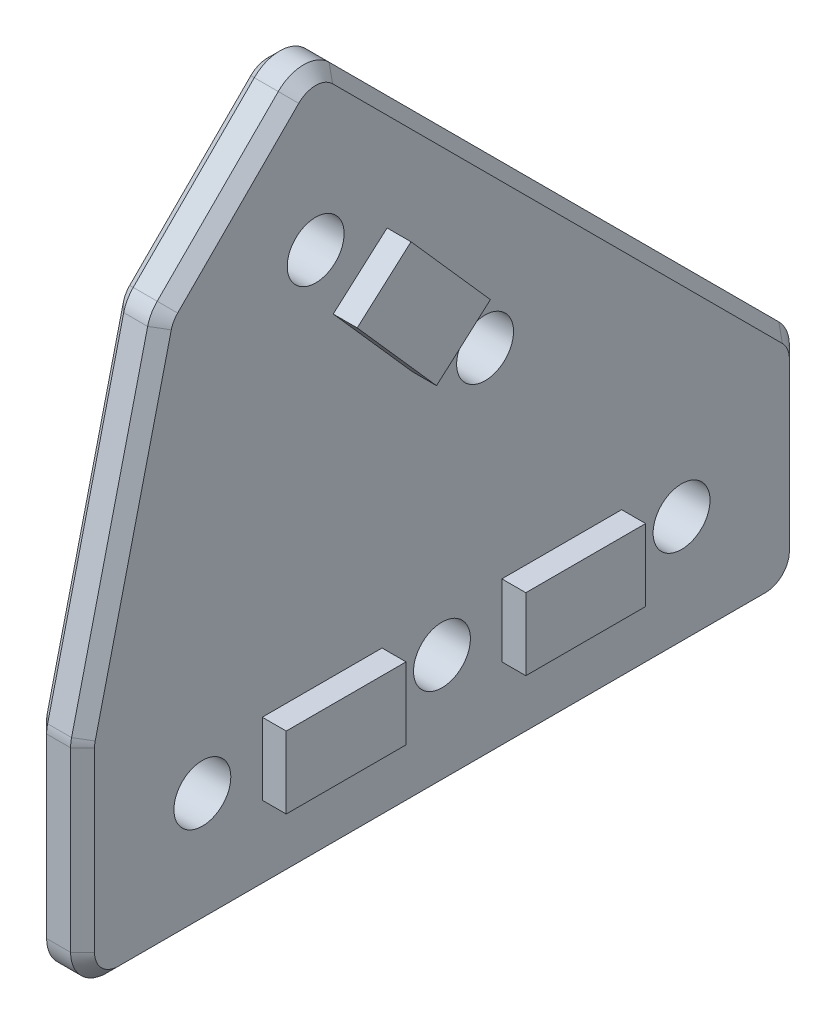
from build123d import *

# Parameters (mm, degrees)
BOSS_EXTRUDE1_DEPTH      = 4
SKETCH2_R                = 2.375
CUT_EXTRUDE1_DEPTH       = 98.803788642
LPATTERN1_COUNT          = 3
LPATTERN1_PITCH          = 20
SKETCH2_4_R              = 2.375
CUT_EXTRUDE2_DEPTH       = 98.803788642
LPATTERN2_COUNT          = 2
LPATTERN2_PITCH          = 20
FILLET1_R                = 3
CHANFRO1_SIZE            = 1
ESBO_O1_W                = 10
ESBO_O1_H                = 6
RESSALTO_EXTRUS_O1_DEPTH = 2


with BuildPart() as part:
    # Sketch1 → Boss-Extrude1 (new body)
    with BuildSketch(Plane(origin=(0, 0, 0), x_dir=(0, 0, -1), z_dir=(1, 0, 0))):
        Polygon((-78.140120378, 0), (-18.140120378, 0), (-18.140120378, 18.140120378), (-58.68306962, 58.68306962), (-71.510071751, 45.856067489), (-78.140120378, 18.140120378), align=None)
    extrude(amount=BOSS_EXTRUDE1_DEPTH)

    # Sketch2 → Cut-Extrude1 (cut, through all)
    with BuildSketch(Plane(origin=(4, 0, 0), x_dir=(0, 0, -1), z_dir=(1, 0, 0))):
        with Locations((-28.140120378, 10)):
            Circle(SKETCH2_R)
    cut_extrude1 = extrude(amount=-CUT_EXTRUDE1_DEPTH, mode=Mode.SUBTRACT)

    # LPattern1: Cut-Extrude1 ×3
    with Locations(*[(0, 0, i * LPATTERN1_PITCH) for i in range(1, LPATTERN1_COUNT)]):
        add(cut_extrude1, mode=Mode.SUBTRACT)

    # Sketch2_4 → Cut-Extrude2 (cut, through all)
    with BuildSketch(Plane(origin=(4, 0, 0), x_dir=(0, 0, -1), z_dir=(1, 0, 0))):
        with Locations((-58.68306962, 44.540933996)):
            Circle(SKETCH2_4_R)
    cut_extrude2 = extrude(amount=-CUT_EXTRUDE2_DEPTH, mode=Mode.SUBTRACT)

    # LPattern2: Cut-Extrude2 ×2
    with Locations(*[Vector(0, -0.7071067811865476, -0.7071067811865476) * (i * LPATTERN2_PITCH) for i in range(1, LPATTERN2_COUNT)]):
        add(cut_extrude2, mode=Mode.SUBTRACT)

    # Fillet1
    fillet1_edges = [part.edges().sort_by_distance(p)[0] for p in [
        (2, 0, 18.140120378),
        (2, 18.140120378, 18.140120378),
        (2, 58.68306962, 58.68306962),
        (2, 0, 78.140120378),
        (2, 18.140120378, 78.140120378),
        (2, 45.856067489, 71.510071751),
    ]]
    fillet(fillet1_edges, radius=FILLET1_R)

    # Chanfro1
    chanfro1_edges = [part.edges().sort_by_distance(p)[0] for p in [
        (4, 0, 48.140120378),
        (4, 0.878679656, 19.018800034),
        (4, 0.878679656, 77.261440721),
        (4, 9.948739845, 18.140120378),
        (4, 10.393145239, 78.140120378),
        (4, 18.045529988, 18.36848178),
        (4, 18.137684762, 78.119469645),
        (4, 37.790274655, 37.790274655),
        (4, 31.75807492, 74.882512025),
        (4, 45.798751214, 71.407627967),
        (4, 57.440428933, 58.68306962),
        (4, 51.508513622, 65.857625619),
        (0, 0, 48.140120378),
        (0, 0.878679656, 19.018800034),
        (0, 0.878679656, 77.261440721),
        (0, 9.948739845, 18.140120378),
        (0, 10.393145239, 78.140120378),
        (0, 18.045529988, 18.36848178),
        (0, 18.137684762, 78.119469645),
        (0, 37.790274655, 37.790274655),
        (0, 31.75807492, 74.882512025),
        (0, 57.440428933, 58.68306962),
        (0, 45.798751214, 71.407627967),
        (0, 51.508513622, 65.857625619),
    ]]
    chamfer(chanfro1_edges, length=CHANFRO1_SIZE)

    # Esboço1 → Ressalto-extrusão1 (add)
    with BuildSketch(Plane(origin=(4, 0, 0), x_dir=(0, 0, -1), z_dir=(1, 0, 0))):
        Polygon((-57.21666665, 39.183379746), (-50.59244791, 31.692069708), (-46.097661887, 35.666600952), (-52.721880627, 43.15791099), align=None)
        with Locations((-58.140120378, 10)):
            Rectangle(ESBO_O1_W, ESBO_O1_H)
        with Locations((-38.140120378, 10)):
            Rectangle(ESBO_O1_W, ESBO_O1_H)
    extrude(amount=RESSALTO_EXTRUS_O1_DEPTH)


solid = part.part
